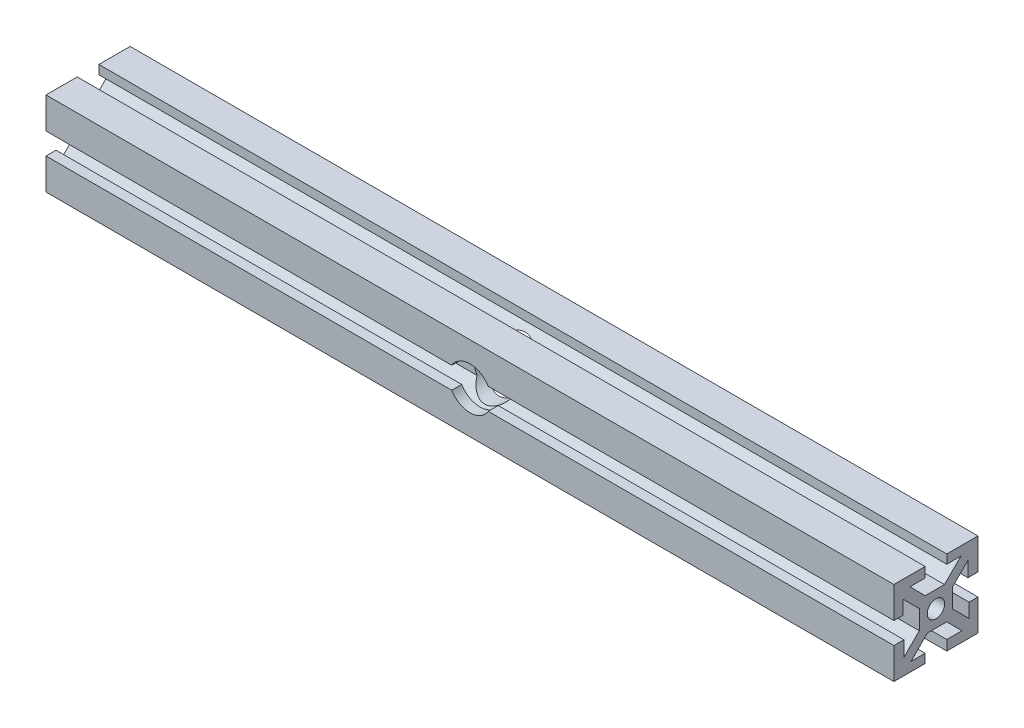
from build123d import *

# Parameters (mm, degrees)
SKETCH1_R           = 2.605
BOSS_EXTRUDE1_DEPTH = 254
CIRPATTERN1_COUNT   = 4
SKETCH2_R           = 6.35
CUT_EXTRUDE1_DEPTH  = 30


with BuildPart() as part:
    # Sketch1 → Boss-Extrude1 (new body)
    with BuildSketch(Plane(origin=(0, 0, 0), x_dir=(0, 0, -1), z_dir=(1, 0, 0))):
        Polygon((5, -5), (5, 3.203948776), (9.596194078, 7.800142853), (9.596194078, 3.24), (12.596194078, 3.24), (12.596194078, 12.596194078), (3.24, 12.596194078), (3.24, 9.921463197), (7.474873734, 9.921463197), (2.553410537, 5), (-5, 5), (-5, -5), align=None)
        Circle(SKETCH1_R, mode=Mode.SUBTRACT)
    boss_extrude1 = extrude(amount=BOSS_EXTRUDE1_DEPTH)

    # CirPattern1: Boss-Extrude1 ×4 about axis
    cirpattern1_axis = Axis((0, 0, 0), (1, 0, 0))
    for i in range(1, CIRPATTERN1_COUNT):
        add(boss_extrude1.rotate(cirpattern1_axis, i * 360 / CIRPATTERN1_COUNT))

    # Sketch2 → Cut-Extrude1 (cut)
    with BuildSketch(Plane.XY.offset(12.596194078)):
        with Locations((127, 0)):
            Circle(SKETCH2_R)
    extrude(amount=-CUT_EXTRUDE1_DEPTH, mode=Mode.SUBTRACT)


solid = part.part
